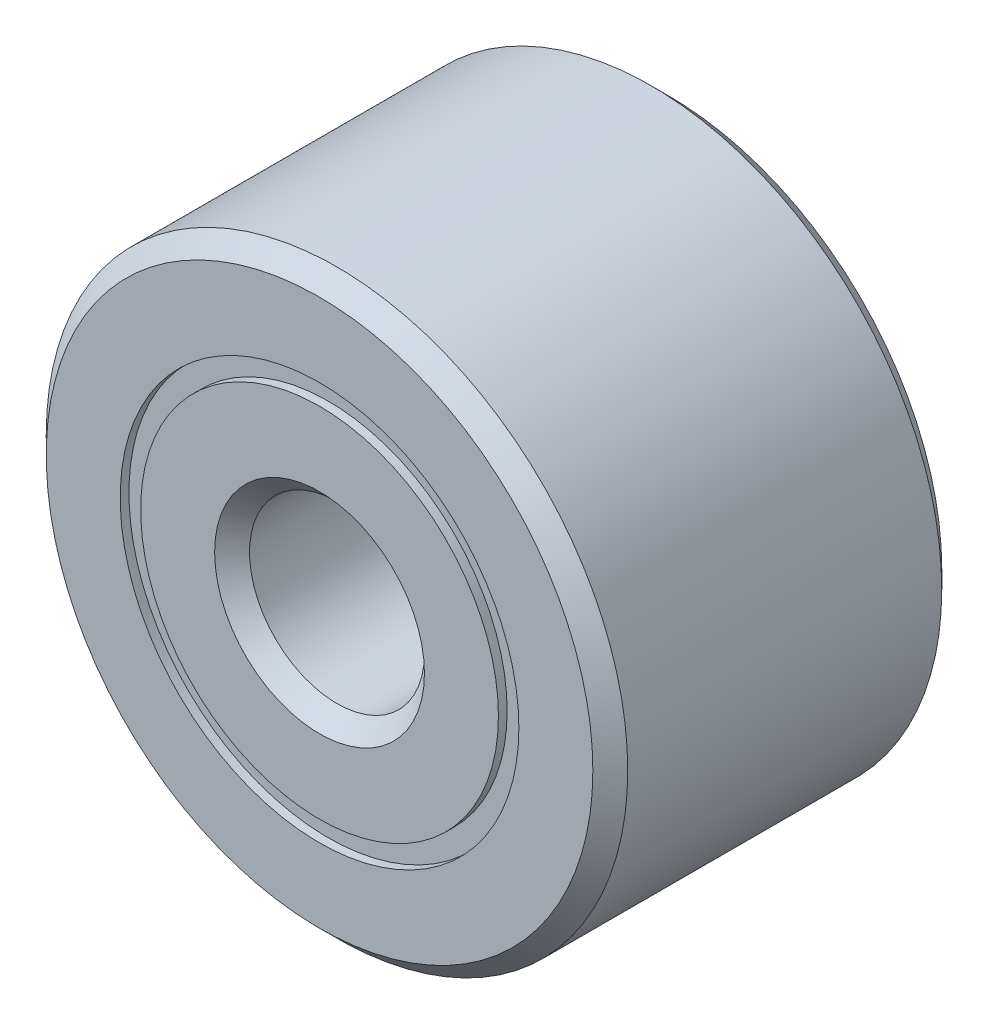
from build123d import *

# Parameters (mm, degrees)
CIRPATTERN1_COUNT = 6
SKETCH5_W         = 0.597346019
SKETCH5_H         = 0.13956044


with BuildPart() as part:
    # Sketch1 → Revolve1 (revolve)
    with BuildSketch(Plane(origin=(0, 0, 0), x_dir=(0, 0, -1), z_dir=(1, 0, 0))):
        with BuildLine():
            Line((1.0715625, 1.984375), (-1.0715625, 1.984375))
            Line((-1.0715625, 1.984375), (-1.190625, 1.8653125))
            Line((-1.190625, 1.8653125), (-1.190625, 1.36041772))
            Line((-1.190625, 1.36041772), (-0.529166667, 1.36041772))
            ThreePointArc((-0.529166667, 1.36041772), (0, 1.824385231), (0.529166667, 1.36041772))
            Line((0.529166667, 1.36041772), (1.190625, 1.36041772))
            Line((1.190625, 1.36041772), (1.190625, 1.8653125))
            Line((1.190625, 1.8653125), (1.0715625, 1.984375))
        make_face()
    revolve(axis=Axis((0, 0, 1.190625), (0, 0, -1)))


with BuildPart() as body_2:
    # Sketch3 → Revolve3 (revolve)
    with BuildSketch(Plane(origin=(0, 0, 0), x_dir=(0, 0, -1), z_dir=(1, 0, 0))):
        with BuildLine():
            Line((-0.529166667, 1.22085728), (-1.190625, 1.22085728))
            Line((-1.190625, 1.22085728), (-1.190625, 0.7159625))
            Line((-1.190625, 0.7159625), (-1.0715625, 0.5969))
            Line((-1.0715625, 0.5969), (1.0715625, 0.5969))
            Line((1.0715625, 0.5969), (1.190625, 0.7159625))
            Line((1.190625, 0.7159625), (1.190625, 1.22085728))
            Line((1.190625, 1.22085728), (0.529166667, 1.22085728))
            ThreePointArc((0.529166667, 1.22085728), (0, 0.756889769), (-0.529166667, 1.22085728))
        make_face()
    revolve(axis=Axis((0, 0, 1.190625), (0, 0, -1)))


with BuildPart() as body_3:
    # Sketch4 → Revolve4 (revolve)
    with BuildSketch(Plane(origin=(0, 0, 0), x_dir=(0, 0, -1), z_dir=(1, 0, 0))):
        with BuildLine():
            Line((-0.533747731, 1.2906375), (0.533747731, 1.2906375))
            ThreePointArc((0.533747731, 1.2906375), (0, 1.824385231), (-0.533747731, 1.2906375))
        make_face()
    revolve(axis=Axis((0, 1.2906375, 0.533747731), (0, 0, -1)))


with BuildPart() as cirpattern1_1:
    # CirPattern1: pattern copy
    add(body_3.part.rotate(Axis((0, 0, -1.190625), (0, 0, 1)), 1 * 360 / CIRPATTERN1_COUNT))


with BuildPart() as cirpattern1_2:
    # CirPattern1: pattern copy
    add(body_3.part.rotate(Axis((0, 0, -1.190625), (0, 0, 1)), 2 * 360 / CIRPATTERN1_COUNT))


with BuildPart() as cirpattern1_3:
    # CirPattern1: pattern copy
    add(body_3.part.rotate(Axis((0, 0, -1.190625), (0, 0, 1)), 3 * 360 / CIRPATTERN1_COUNT))


with BuildPart() as cirpattern1_4:
    # CirPattern1: pattern copy
    add(body_3.part.rotate(Axis((0, 0, -1.190625), (0, 0, 1)), 4 * 360 / CIRPATTERN1_COUNT))


with BuildPart() as cirpattern1_5:
    # CirPattern1: pattern copy
    add(body_3.part.rotate(Axis((0, 0, -1.190625), (0, 0, 1)), 5 * 360 / CIRPATTERN1_COUNT))


with BuildPart() as body_9:
    # Sketch5 → Revolve5 (revolve)
    with BuildSketch(Plane(origin=(0, 0, 0), x_dir=(0, 0, -1), z_dir=(1, 0, 0))):
        with Locations((-0.832420741, 1.2906375)):
            Rectangle(SKETCH5_W, SKETCH5_H)
        with Locations((0.832420741, 1.2906375)):
            Rectangle(SKETCH5_W, SKETCH5_H)
    revolve(axis=Axis((0, 0, 1.190625), (0, 0, -1)))


solid = Compound([part.part, body_2.part, body_3.part, cirpattern1_1.part, cirpattern1_2.part, cirpattern1_3.part, cirpattern1_4.part, cirpattern1_5.part, body_9.part])
